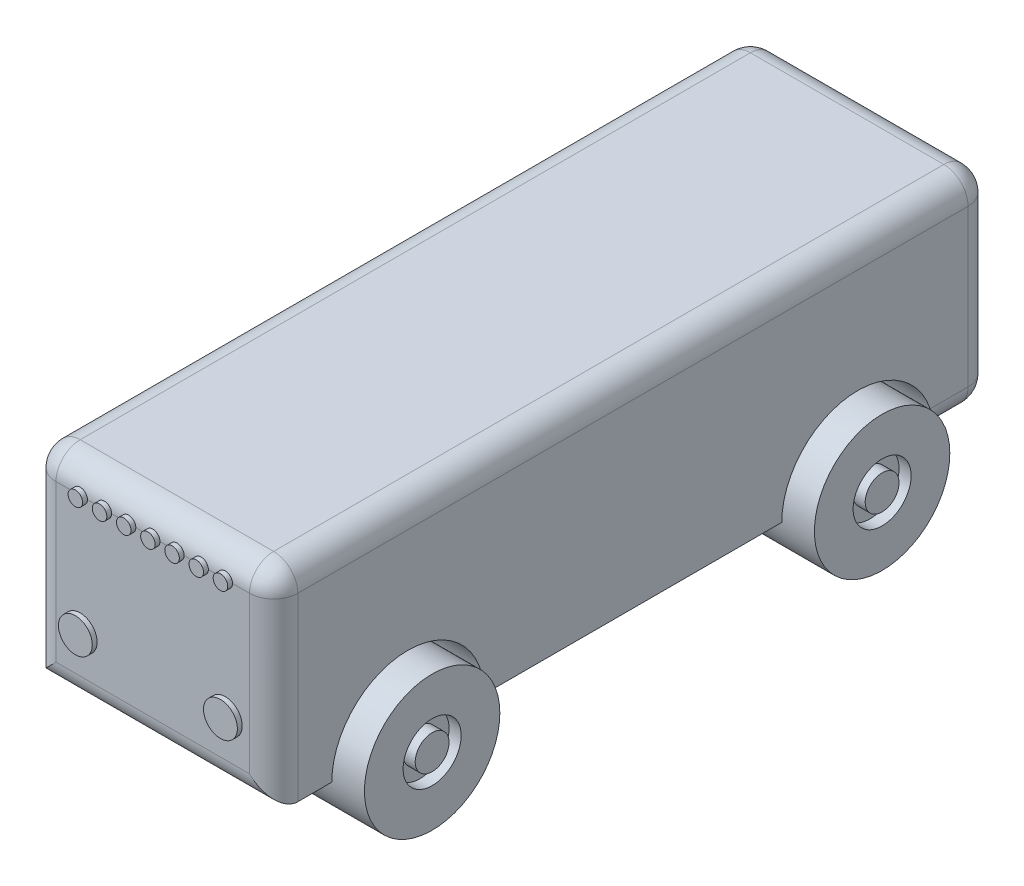
from build123d import *

# Parameters (mm, degrees)
EXTRUDE_1_DEPTH        = 100
SKETCH_2_R             = 28
EXTRUDE_2_DEPTH        = 30
EXTRUDE_2_DEPTH_BACK   = 10
EXTRUDE_2_2_DEPTH      = 30
EXTRUDE_2_2_DEPTH_BACK = 10
SKETCH_3_R             = 28
EXTRUDE_3_DEPTH        = 10
EXTRUDE_3_DEPTH_BACK   = 30
EXTRUDE_3_2_DEPTH      = 10
EXTRUDE_3_2_DEPTH_BACK = 30
EXTRUDE_5_DEPTH        = 10
EXTRUDE_7_DEPTH        = 100
FILLET_1_R             = 10
FILLET_2_R             = 10
SKETCH_10_R            = 7
EXTRUDE_9_DEPTH        = 2
SKETCH_11_R            = 12
CUT_EXTRUDE_1_DEPTH    = 5
SKETCH_12_R            = 7
EXTRUDE_11_DEPTH       = 5
SKETCH_13_R            = 12
CUT_EXTRUDE_2_DEPTH    = 5
SKETCH_14_R            = 7
EXTRUDE_12_DEPTH       = 5
SKETCH_15_R            = 12
CUT_EXTRUDE_3_DEPTH    = 5
SKETCH_16_R            = 7
EXTRUDE_13_DEPTH       = 5
SKETCH_17_R            = 12
CUT_EXTRUDE_4_DEPTH    = 5
SKETCH_18_R            = 7
EXTRUDE_14_DEPTH       = 5
SKETCH_21_W            = 57.37750778
SKETCH_21_H            = 64.658586112
EXTRUDE_15_DEPTH       = 1


with BuildPart() as part:
    # Эскиз1 → Бобышка-Вытянуть1 (new body)
    with BuildSketch(Plane(origin=(0, 0, 0), x_dir=(0, 0, -1), z_dir=(1, 0, 0))):
        with BuildLine():
            Line((-61.537852792, -17.333832318), (61.537852792, -17.333832318))
            ThreePointArc((61.537852792, -17.333832318), (93.037852792, 14.166167682), (124.537852792, -17.333832318))
            Line((124.537852792, -17.333832318), (148.575705584, -17.333832318))
            Line((148.575705584, -17.333832318), (148.575705584, 17.333832318))
            Line((148.575705584, 17.333832318), (148.575705584, 32.333832318))
            Line((148.575705584, 32.333832318), (-148.575705584, 32.333832318))
            Line((-148.575705584, 32.333832318), (-148.575705584, 17.333832318))
            Line((-148.575705584, 17.333832318), (-148.575705584, -17.333832318))
            Line((-148.575705584, -17.333832318), (-124.537852792, -17.333832318))
            ThreePointArc((-124.537852792, -17.333832318), (-93.037852792, 14.166167682), (-61.537852792, -17.333832318))
        make_face()
    extrude(amount=EXTRUDE_1_DEPTH)



with BuildPart() as body_2:
    # Эскиз2 → Бобышка-Вытянуть2 (new body, two sides)
    with BuildSketch(Plane(origin=(0, 0, 0), x_dir=(0, 0, -1), z_dir=(1, 0, 0))) as extrude_2_sk:
        with Locations((-93.037852792, -17.333832318)):
            Circle(SKETCH_2_R)
    extrude(amount=EXTRUDE_2_DEPTH)
    extrude(extrude_2_sk.sketch, amount=-EXTRUDE_2_DEPTH_BACK)


with BuildPart() as body_3:
    # Эскиз2 → Extrude 2 2 (new body, two sides)
    with BuildSketch(Plane(origin=(0, 0, 0), x_dir=(0, 0, -1), z_dir=(1, 0, 0))) as extrude_2_2_sk:
        with Locations((93.037852792, -17.333832318)):
            Circle(SKETCH_2_R)
    extrude(amount=EXTRUDE_2_2_DEPTH)
    extrude(extrude_2_2_sk.sketch, amount=-EXTRUDE_2_2_DEPTH_BACK)


with BuildPart() as body_4:
    # Эскиз3 → Бобышка-Вытянуть3 (new body, two sides)
    with BuildSketch(Plane(origin=(100, 0, 0), x_dir=(0, 0, -1), z_dir=(1, 0, 0))) as extrude_3_sk:
        with Locations((-93.037852792, -17.333832318)):
            Circle(SKETCH_3_R)
    extrude(amount=EXTRUDE_3_DEPTH)
    extrude(extrude_3_sk.sketch, amount=-EXTRUDE_3_DEPTH_BACK)


with BuildPart() as body_5:
    # Эскиз3 → Extrude 3 2 (new body, two sides)
    with BuildSketch(Plane(origin=(100, 0, 0), x_dir=(0, 0, -1), z_dir=(1, 0, 0))) as extrude_3_2_sk:
        with Locations((93.037852792, -17.333832318)):
            Circle(SKETCH_3_R)
    extrude(amount=EXTRUDE_3_2_DEPTH)
    extrude(extrude_3_2_sk.sketch, amount=-EXTRUDE_3_2_DEPTH_BACK)


with BuildPart() as part_1:
    add(part.part)

    add(body_2.part)  # Бобышка-Вытянуть5 merges body 2

    add(body_3.part)  # Бобышка-Вытянуть5 merges body 3

    add(body_4.part)  # Бобышка-Вытянуть5 merges body 4

    add(body_5.part)  # Бобышка-Вытянуть5 merges body 5
    # Эскиз4 → Бобышка-Вытянуть5 (add)
    with BuildSketch(Plane.XZ.offset(17.333832318)):
        Polygon((45, 61.537852792), (55, 61.537852792), (55, 88.037852792), (70.061323461, 88.037852792), (70.061323461, 98.037852792), (55, 98.037852792), (55, 124.537852792), (45, 124.537852792), (45, 98.037852792), (29.938676539, 98.037852792), (29.938676539, 88.037852792), (45, 88.037852792), align=None)
        Polygon((45, -61.537852792), (55, -61.537852792), (55, -88.037852792), (70.061323461, -88.037852792), (70.061323461, -98.037852792), (55, -98.037852792), (55, -124.537852792), (45, -124.537852792), (45, -98.037852792), (29.938676539, -98.037852792), (29.938676539, -88.037852792), (45, -88.037852792), align=None)
    extrude(amount=-EXTRUDE_5_DEPTH)

    # Эскиз7 → Бобышка-Вытянуть7 (add)
    with BuildSketch(Plane(origin=(0, 0, 0), x_dir=(0, 0, -1), z_dir=(1, 0, 0))):
        with BuildLine():
            Line((-148.575705584, 32.333832318), (148.575705584, 32.333832318))
            Line((148.575705584, 32.333832318), (148.575705584, 57.333832318))
            ThreePointArc((148.575705584, 57.333832318), (145.646773396, 64.40490013), (138.575705584, 67.333832318))
            Line((138.575705584, 67.333832318), (-138.575705584, 67.333832318))
            ThreePointArc((-138.575705584, 67.333832318), (-145.646773396, 64.40490013), (-148.575705584, 57.333832318))
            Line((-148.575705584, 57.333832318), (-148.575705584, 32.333832318))
        make_face()
    extrude(amount=EXTRUDE_7_DEPTH)

    # Скругление1
    fillet_1_edges = [part_1.edges().sort_by_distance(p)[0] for p in [
        (0, 7.5, 148.575705584),
        (0, 7.5, -148.575705584),
        (0, 64.40490013, -145.646773396),
        (0, 67.333832318, 0),
        (0, 64.40490013, 145.646773396),
        (100, 64.40490013, -145.646773396),
        (100, 67.333832318, 0),
        (100, 64.40490013, 145.646773396),
        (50, -17.333832318, 148.575705584),
        (100, 7.5, -148.575705584),
        (100, 7.5, 148.575705584),
    ]]
    fillet(fillet_1_edges, radius=FILLET_1_R)

    # Скругление2
    fillet_2_edges = [part_1.edges().sort_by_distance(p)[0] for p in [
        (0, -17.333832318, -131.556779188),
        (50, -17.333832318, -148.575705584),
        (2.928932188, -17.333832318, -145.646773396),
        (97.071067812, -17.333832318, -145.646773396),
        (100, -17.333832318, -131.556779188),
    ]]
    fillet(fillet_2_edges, radius=FILLET_2_R)

    # Эскиз10 → Бобышка-Вытянуть9 (add)
    with BuildSketch(Plane.XY.offset(148.575705584)):
        with Locations((20, 8.320169556)):
            Circle(SKETCH_10_R)
        with Locations((80, 8.320169556)):
            Circle(SKETCH_10_R)
        with BuildLine():
            ThreePointArc((23, 57.333832318), (22.121320344, 59.455152662), (20, 60.333832318))
            ThreePointArc((20, 60.333832318), (17.878679656, 59.455152662), (17, 57.333832318))
            Line((17, 57.333832318), (23, 57.333832318))
        make_face()
        with BuildLine():
            ThreePointArc((20, 54.333832318), (22.121320344, 55.212511975), (23, 57.333832318))
            Line((23, 57.333832318), (17, 57.333832318))
            ThreePointArc((17, 57.333832318), (17.878679656, 55.212511975), (20, 54.333832318))
        make_face()
        with BuildLine():
            ThreePointArc((33, 57.333832318), (32.121320344, 59.455152662), (30, 60.333832318))
            ThreePointArc((30, 60.333832318), (27.878679656, 59.455152662), (27, 57.333832318))
            Line((27, 57.333832318), (33, 57.333832318))
        make_face()
        with BuildLine():
            ThreePointArc((30, 54.333832318), (32.121320344, 55.212511975), (33, 57.333832318))
            Line((33, 57.333832318), (27, 57.333832318))
            ThreePointArc((27, 57.333832318), (27.878679656, 55.212511975), (30, 54.333832318))
        make_face()
        with BuildLine():
            ThreePointArc((43, 57.333832318), (42.121320344, 59.455152662), (40, 60.333832318))
            ThreePointArc((40, 60.333832318), (37.878679656, 59.455152662), (37, 57.333832318))
            Line((37, 57.333832318), (43, 57.333832318))
        make_face()
        with BuildLine():
            ThreePointArc((40, 54.333832318), (42.121320344, 55.212511975), (43, 57.333832318))
            Line((43, 57.333832318), (37, 57.333832318))
            ThreePointArc((37, 57.333832318), (37.878679656, 55.212511975), (40, 54.333832318))
        make_face()
        with BuildLine():
            ThreePointArc((53, 57.333832318), (52.121320344, 59.455152662), (50, 60.333832318))
            ThreePointArc((50, 60.333832318), (47.878679656, 59.455152662), (47, 57.333832318))
            Line((47, 57.333832318), (53, 57.333832318))
        make_face()
        with BuildLine():
            ThreePointArc((50, 54.333832318), (52.121320344, 55.212511975), (53, 57.333832318))
            Line((53, 57.333832318), (47, 57.333832318))
            ThreePointArc((47, 57.333832318), (47.878679656, 55.212511975), (50, 54.333832318))
        make_face()
        with BuildLine():
            ThreePointArc((63, 57.333832318), (62.121320344, 59.455152662), (60, 60.333832318))
            ThreePointArc((60, 60.333832318), (57.878679656, 59.455152662), (57, 57.333832318))
            Line((57, 57.333832318), (63, 57.333832318))
        make_face()
        with BuildLine():
            ThreePointArc((60, 54.333832318), (62.121320344, 55.212511975), (63, 57.333832318))
            Line((63, 57.333832318), (57, 57.333832318))
            ThreePointArc((57, 57.333832318), (57.878679656, 55.212511975), (60, 54.333832318))
        make_face()
        with BuildLine():
            ThreePointArc((73, 57.333832318), (72.121320344, 59.455152662), (70, 60.333832318))
            ThreePointArc((70, 60.333832318), (67.878679656, 59.455152662), (67, 57.333832318))
            Line((67, 57.333832318), (73, 57.333832318))
        make_face()
        with BuildLine():
            ThreePointArc((70, 54.333832318), (72.121320344, 55.212511975), (73, 57.333832318))
            Line((73, 57.333832318), (67, 57.333832318))
            ThreePointArc((67, 57.333832318), (67.878679656, 55.212511975), (70, 54.333832318))
        make_face()
        with BuildLine():
            ThreePointArc((83, 57.333832318), (82.121320344, 59.455152662), (80, 60.333832318))
            ThreePointArc((80, 60.333832318), (77.878679656, 59.455152662), (77, 57.333832318))
            Line((77, 57.333832318), (83, 57.333832318))
        make_face()
        with BuildLine():
            ThreePointArc((80, 54.333832318), (82.121320344, 55.212511975), (83, 57.333832318))
            Line((83, 57.333832318), (77, 57.333832318))
            ThreePointArc((77, 57.333832318), (77.878679656, 55.212511975), (80, 54.333832318))
        make_face()
    extrude(amount=EXTRUDE_9_DEPTH)

    # Эскиз11 → Вырез-Вытянуть1 (cut)
    with BuildSketch(Plane.ZY.offset(10)):
        with Locations((-93.037852792, -17.333832318)):
            Circle(SKETCH_11_R)
    extrude(amount=-CUT_EXTRUDE_1_DEPTH, mode=Mode.SUBTRACT)

    # Эскиз12 → Бобышка-Вытянуть11 (add)
    with BuildSketch(Plane.ZY.offset(10)):
        with Locations((-93.037852792, -17.333832318)):
            Circle(SKETCH_12_R)
    extrude(amount=-EXTRUDE_11_DEPTH)

    # Эскиз13 → Вырез-Вытянуть2 (cut)
    with BuildSketch(Plane.ZY.offset(10)):
        with Locations((93.037852792, -17.333832318)):
            Circle(SKETCH_13_R)
    extrude(amount=-CUT_EXTRUDE_2_DEPTH, mode=Mode.SUBTRACT)

    # Эскиз14 → Бобышка-Вытянуть12 (add)
    with BuildSketch(Plane.ZY.offset(5)):
        with Locations((93.037852792, -17.333832318)):
            Circle(SKETCH_14_R)
    extrude(amount=EXTRUDE_12_DEPTH)

    # Эскиз15 → Вырез-Вытянуть3 (cut)
    with BuildSketch(Plane(origin=(110, 0, 0), x_dir=(0, 0, -1), z_dir=(1, 0, 0))):
        with Locations((-93.037852792, -17.333832318)):
            Circle(SKETCH_15_R)
    extrude(amount=-CUT_EXTRUDE_3_DEPTH, mode=Mode.SUBTRACT)

    # Эскиз16 → Бобышка-Вытянуть13 (add)
    with BuildSketch(Plane(origin=(105, 0, 0), x_dir=(0, 0, -1), z_dir=(1, 0, 0))):
        with Locations((-93.037852792, -17.333832318)):
            Circle(SKETCH_16_R)
    extrude(amount=EXTRUDE_13_DEPTH)

    # Эскиз17 → Вырез-Вытянуть4 (cut)
    with BuildSketch(Plane(origin=(110, 0, 0), x_dir=(0, 0, -1), z_dir=(1, 0, 0))):
        with Locations((93.037852792, -17.333832318)):
            Circle(SKETCH_17_R)
    extrude(amount=-CUT_EXTRUDE_4_DEPTH, mode=Mode.SUBTRACT)

    # Эскиз18 → Бобышка-Вытянуть14 (add)
    with BuildSketch(Plane(origin=(105, 0, 0), x_dir=(0, 0, -1), z_dir=(1, 0, 0))):
        with Locations((93.037852792, -17.333832318)):
            Circle(SKETCH_18_R)
    extrude(amount=EXTRUDE_14_DEPTH)

    # Эскиз21 → Бобышка-Вытянуть15 (add)
    with BuildSketch(Plane(origin=(0, 0, -148.575705584), x_dir=(-1, 0, 0), z_dir=(0, 0, -1))):
        with Locations((-50, 25.004539262)):
            Rectangle(SKETCH_21_W, SKETCH_21_H)
    extrude(amount=EXTRUDE_15_DEPTH)


solid = part_1.part
